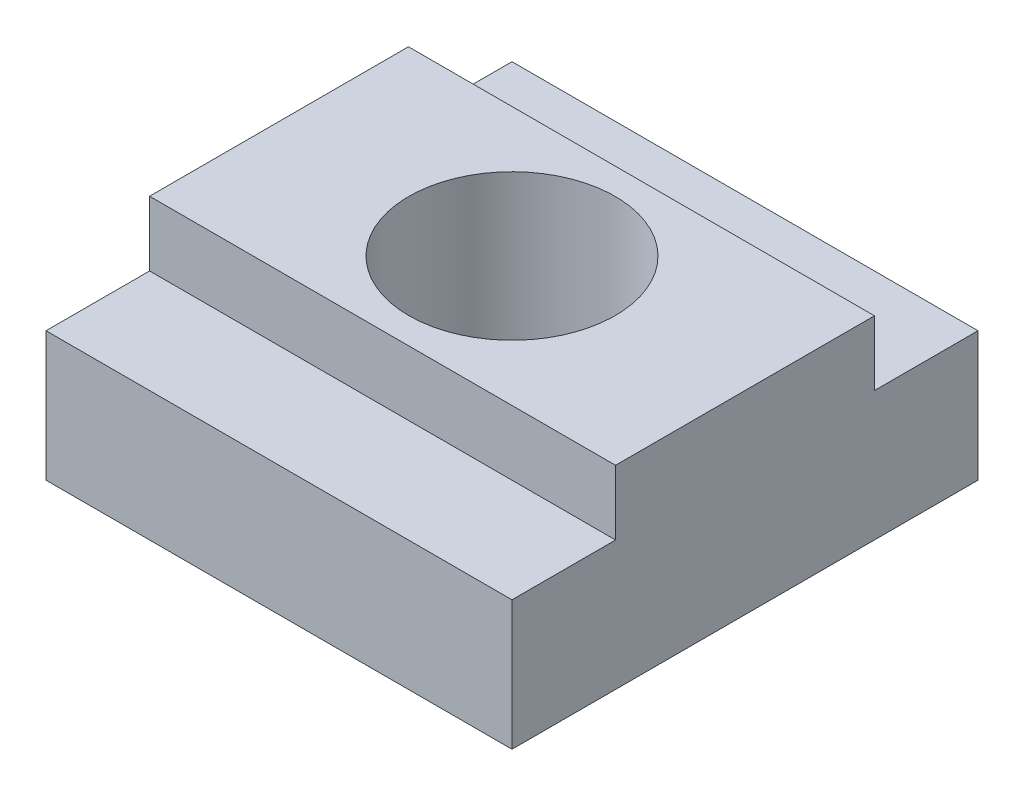
from build123d import *

# Parameters (mm, degrees)
BOSS_EXTRUDE1_DEPTH = 14.2875
SKETCH2_R           = 6.33095
CUT_EXTRUDE1_DEPTH  = 12.90625


with BuildPart() as part:
    # Sketch1 → Boss-Extrude1 (new body, symmetric)
    with BuildSketch(Plane(origin=(0, 0, 0), x_dir=(0, 0, -1), z_dir=(1, 0, 0))):
        Polygon((7.9375, 11.90625), (-7.9375, 11.90625), (-7.9375, 7.9375), (-14.2875, 7.9375), (-14.2875, 0), (14.2875, 0), (14.2875, 7.9375), (7.9375, 7.9375), align=None)
    extrude(amount=BOSS_EXTRUDE1_DEPTH, both=True)

    # Sketch2 → Cut-Extrude1 (cut, through all)
    with BuildSketch(Plane(origin=(0, 11.90625, 0), x_dir=(1, 0, 0), z_dir=(0, 1, 0))):
        Circle(SKETCH2_R)
    extrude(amount=-CUT_EXTRUDE1_DEPTH, mode=Mode.SUBTRACT)


solid = part.part
